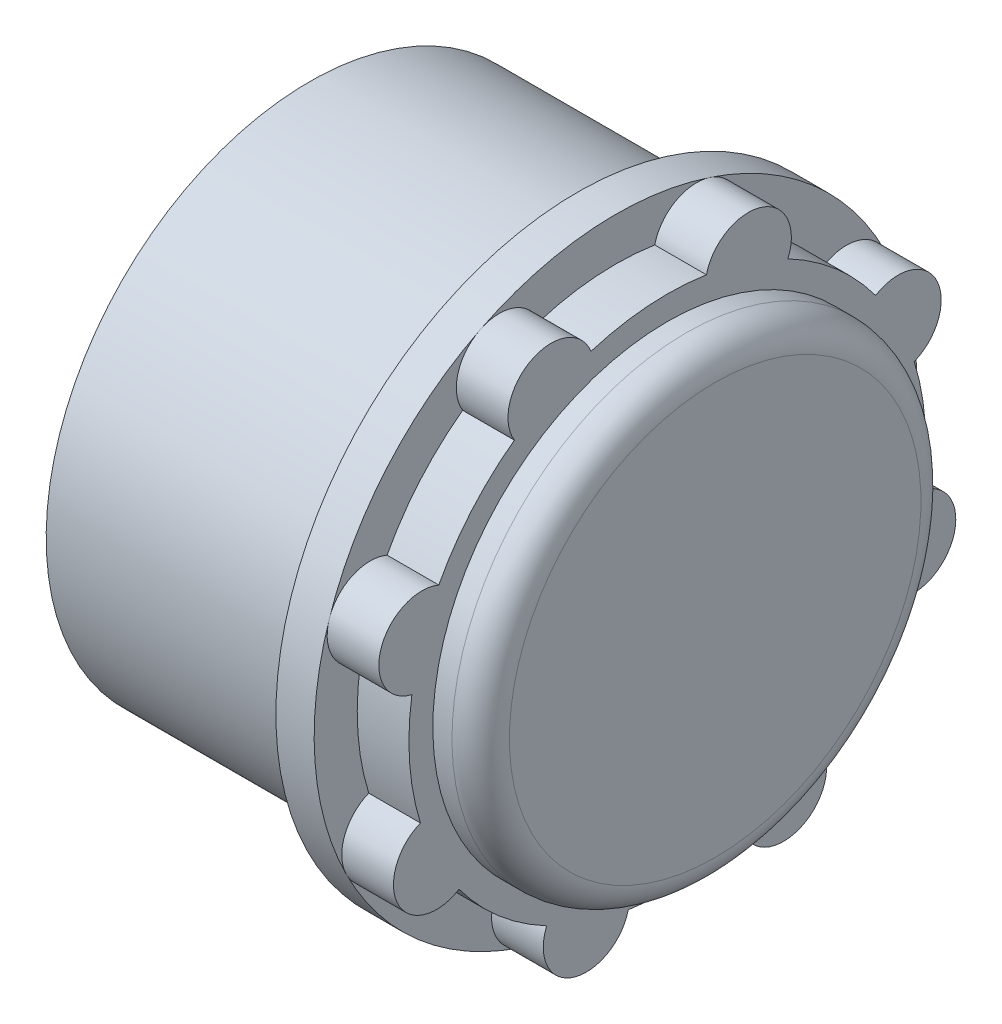
from build123d import *

# Parameters (mm, degrees)
SKETCH1_R           = 15.75
BOSS_EXTRUDE1_DEPTH = 2
BOSS_EXTRUDE2_DEPTH = 2.7
SKETCH3_R           = 12.25
BOSS_EXTRUDE3_DEPTH = 2.5
SKETCH4_R           = 13.75
BOSS_EXTRUDE4_DEPTH = 14
SKETCH5_R           = 11.25
CUT_EXTRUDE1_DEPTH  = 20.5
FILLET1_R           = 1.5
FILLET2_R           = 2


with BuildPart() as part:
    # Sketch1 → Boss-Extrude1 (new body)
    with BuildSketch(Plane.YZ):
        Circle(SKETCH1_R)
    extrude(amount=BOSS_EXTRUDE1_DEPTH)

    # Sketch2 → Boss-Extrude2 (add)
    with BuildSketch(Plane.YZ.offset(2)):
        with BuildLine():
            ThreePointArc((10.880321188, 7.991783959), (8.814480217, 10.225210927), (6.300979972, 11.939332117))
            ThreePointArc((6.300979972, 11.939332117), (4.935582223, 14.956688408), (2.042504262, 13.344593525))
            ThreePointArc((2.042504262, 13.344593525), (-0.997537251, 13.46309472), (-3.986917036, 12.897848369))
            ThreePointArc((-3.986917036, 12.897848369), (-7.085992138, 14.065959456), (-7.991783959, 10.880321188))
            ThreePointArc((-7.991783959, 10.880321188), (-10.225210927, 8.814480217), (-11.939332117, 6.300979972))
            ThreePointArc((-11.939332117, 6.300979972), (-14.956688408, 4.935582223), (-13.344593525, 2.042504262))
            ThreePointArc((-13.344593525, 2.042504262), (-13.46309472, -0.997537251), (-12.897848369, -3.986917036))
            ThreePointArc((-12.897848369, -3.986917036), (-14.065959456, -7.085992138), (-10.880321188, -7.991783959))
            ThreePointArc((-10.880321188, -7.991783959), (-8.814480217, -10.225210927), (-6.300979972, -11.939332117))
            ThreePointArc((-6.300979972, -11.939332117), (-4.935582223, -14.956688408), (-2.042504262, -13.344593525))
            ThreePointArc((-2.042504262, -13.344593525), (0.997537251, -13.46309472), (3.986917036, -12.897848369))
            ThreePointArc((3.986917036, -12.897848369), (7.085992138, -14.065959456), (7.991783959, -10.880321188))
            ThreePointArc((7.991783959, -10.880321188), (10.225210927, -8.814480217), (11.939332117, -6.300979972))
            ThreePointArc((11.939332117, -6.300979972), (14.956688408, -4.935582223), (13.344593525, -2.042504262))
            ThreePointArc((13.344593525, -2.042504262), (13.46309472, 0.997537251), (12.897848369, 3.986917036))
            ThreePointArc((12.897848369, 3.986917036), (14.065959456, 7.085992138), (10.880321188, 7.991783959))
        make_face()
    extrude(amount=BOSS_EXTRUDE2_DEPTH)

    # Sketch3 → Boss-Extrude3 (add)
    with BuildSketch(Plane.YZ.offset(4.7)):
        Circle(SKETCH3_R)
    extrude(amount=BOSS_EXTRUDE3_DEPTH)

    # Sketch4 → Boss-Extrude4 (add)
    with BuildSketch(Plane(origin=(0, 0, 0), x_dir=(0, -1, 0), z_dir=(-1, 0, 0))):
        Circle(SKETCH4_R)
    extrude(amount=BOSS_EXTRUDE4_DEPTH)

    # Sketch5 → Cut-Extrude1 (cut)
    with BuildSketch(Plane(origin=(-14, 0, 0), x_dir=(0, -1, 0), z_dir=(-1, 0, 0))):
        Circle(SKETCH5_R)
    extrude(amount=-CUT_EXTRUDE1_DEPTH, mode=Mode.SUBTRACT)

    # Fillet1
    fillet1_edges = [part.edges().sort_by_distance(p)[0] for p in [
        (7.2, -12.25, 0),
    ]]
    fillet(fillet1_edges, radius=FILLET1_R)

    # Fillet2
    fillet2_edges = [part.edges().sort_by_distance(p)[0] for p in [
        (6.5, 11.25, 0),
    ]]
    fillet(fillet2_edges, radius=FILLET2_R)


solid = part.part
